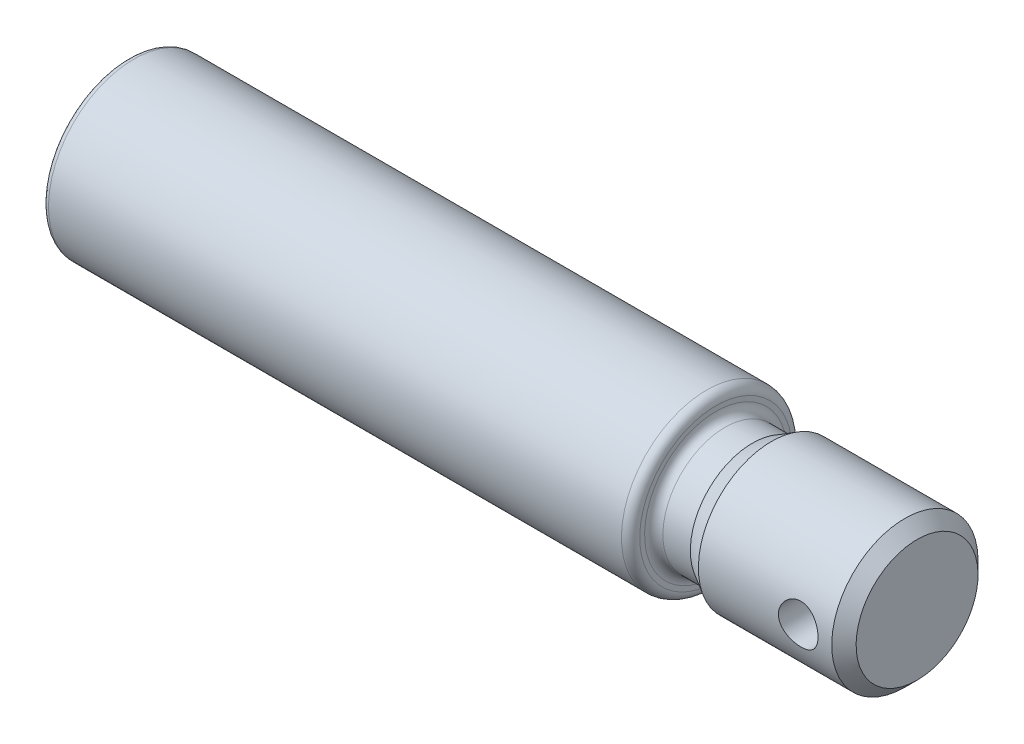
from build123d import *

# Parameters (mm, degrees)
SKETCH2_R       = 3.25
F_6_5_HUL_DEPTH = 25


with BuildPart() as part:
    # Sketch1 → Base-Revolve (revolve)
    with BuildSketch(Plane.XY):
        with BuildLine():
            Line((1, 14), (95, 14))
            ThreePointArc((95, 14), (96.060660172, 13.560660172), (96.5, 12.5))
            Line((96.5, 12.5), (96.5, 11.7))
            ThreePointArc((96.5, 11.7), (96.939339828, 10.639339828), (98, 10.2))
            Line((98, 10.2), (102.5, 10.2))
            Line((102.5, 10.2), (105.617691454, 12))
            Line((105.617691454, 12), (127.5, 12))
            Line((127.5, 12), (129.5, 10))
            Line((129.5, 10), (129.5, 0))
            Line((129.5, 0), (0, 0))
            Line((0, 0), (0, 13))
            ThreePointArc((0, 13), (0.292893219, 13.707106781), (1, 14))
        make_face()
    revolve(axis=Axis((-12.994157099, 0, 0), (1, 0, 0)))

    # Sketch2 → ø6.5 hul (cut, symmetric)
    with BuildSketch(Plane.XY):
        with Locations((122, 0)):
            Circle(SKETCH2_R)
    extrude(amount=F_6_5_HUL_DEPTH, both=True, mode=Mode.SUBTRACT)


solid = part.part
